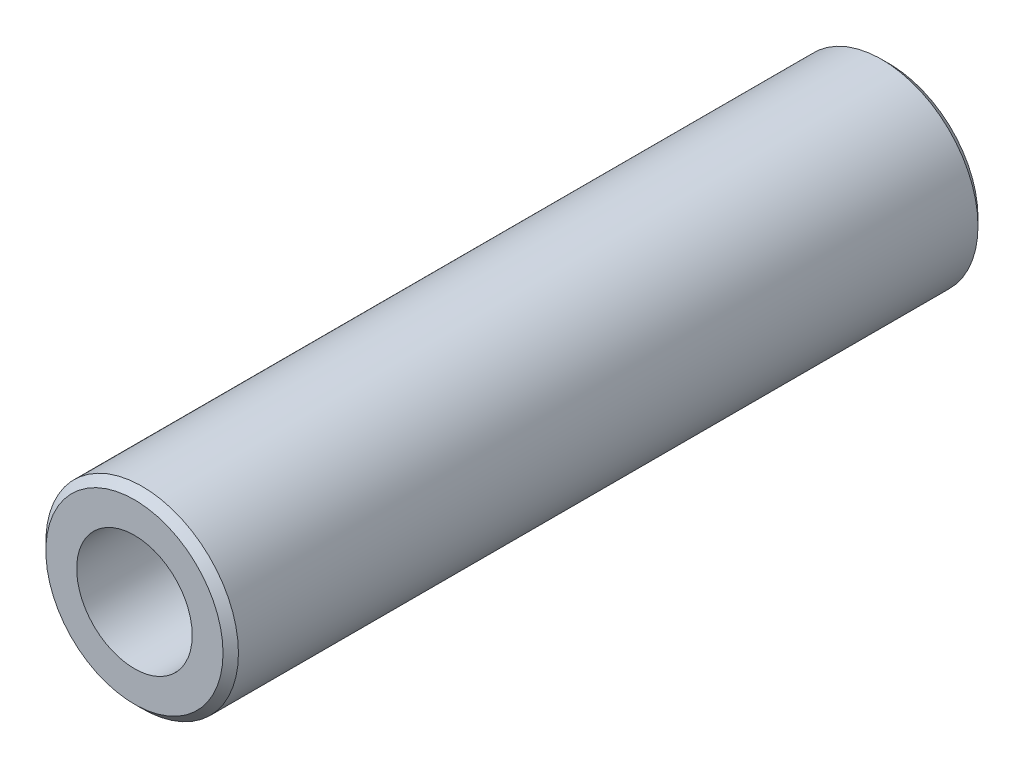
from build123d import *

# Parameters (mm, degrees)
SKETCH1_R           = 6.25
SKETCH1_R_2         = 3.75
EXTRUDE_THIN1_DEPTH = 24.5
CHAMFER1_SIZE       = 0.5


with BuildPart() as part:
    # Sketch1 → Extrude-Thin1 (new body, symmetric)
    with BuildSketch(Plane.XY):
        Circle(SKETCH1_R)
        Circle(SKETCH1_R_2, mode=Mode.SUBTRACT)
    extrude(amount=EXTRUDE_THIN1_DEPTH, both=True)

    # Chamfer1
    chamfer1_edges = [part.edges().sort_by_distance(p)[0] for p in [
        (-6.25, 0, -24.5),
        (-6.25, 0, 24.5),
    ]]
    chamfer(chamfer1_edges, length=CHAMFER1_SIZE)


solid = part.part
